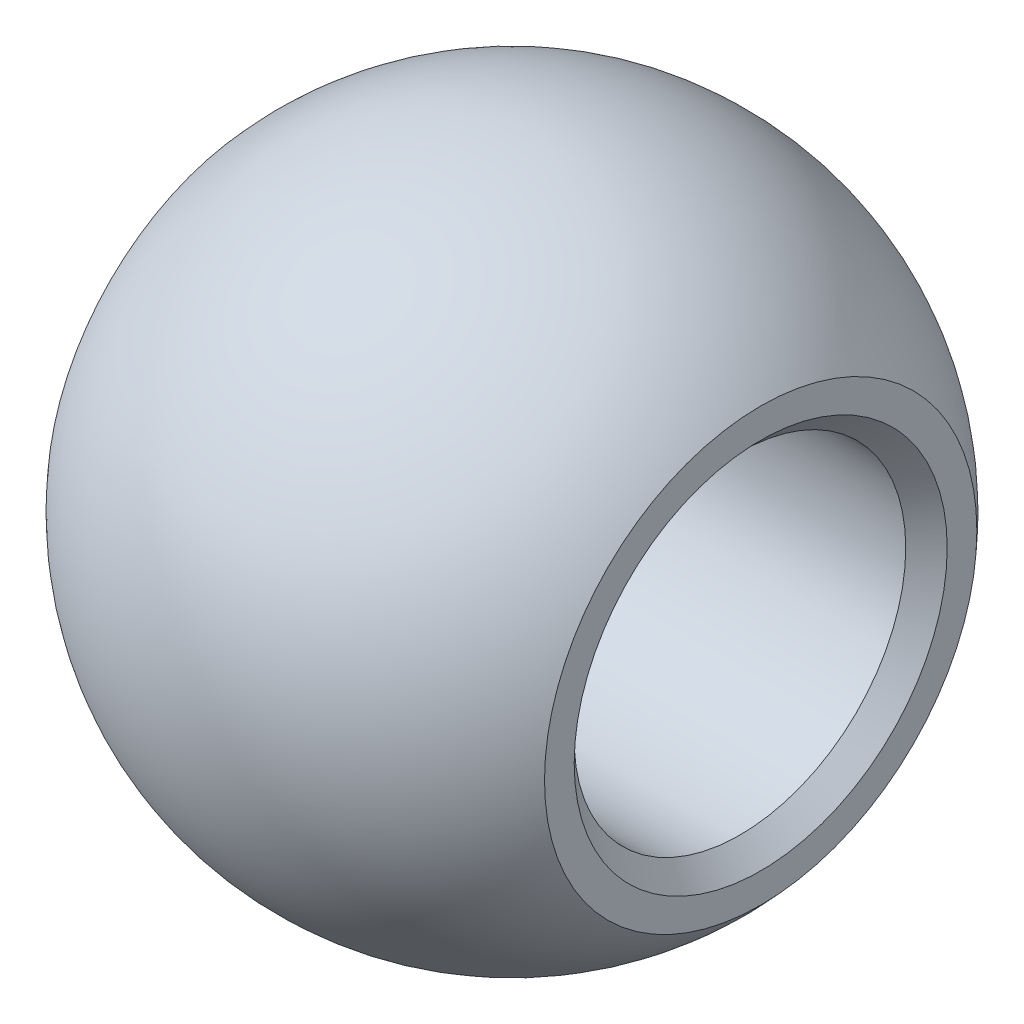
from build123d import *

# Parameters (mm, degrees)
CHAMFER1_SIZE = 0.5


with BuildPart() as part:
    # Sketch1 → Revolve1 (revolve)
    with BuildSketch(Plane.XY):
        with BuildLine():
            Line((6, 5.215601595), (6, 4))
            Line((6, 4), (-6, 4))
            Line((-6, 4), (-6, 5.215601595))
            ThreePointArc((-6, 5.215601595), (0, 7.95), (6, 5.215601595))
        make_face()
    revolve(axis=Axis((7.95, 0, 0), (-1, 0, 0)))

    # Chamfer1
    chamfer1_edges = [part.edges().sort_by_distance(p)[0] for p in [
        (6, -4, 0),
        (-6, -4, 0),
    ]]
    chamfer(chamfer1_edges, length=CHAMFER1_SIZE)


solid = part.part
